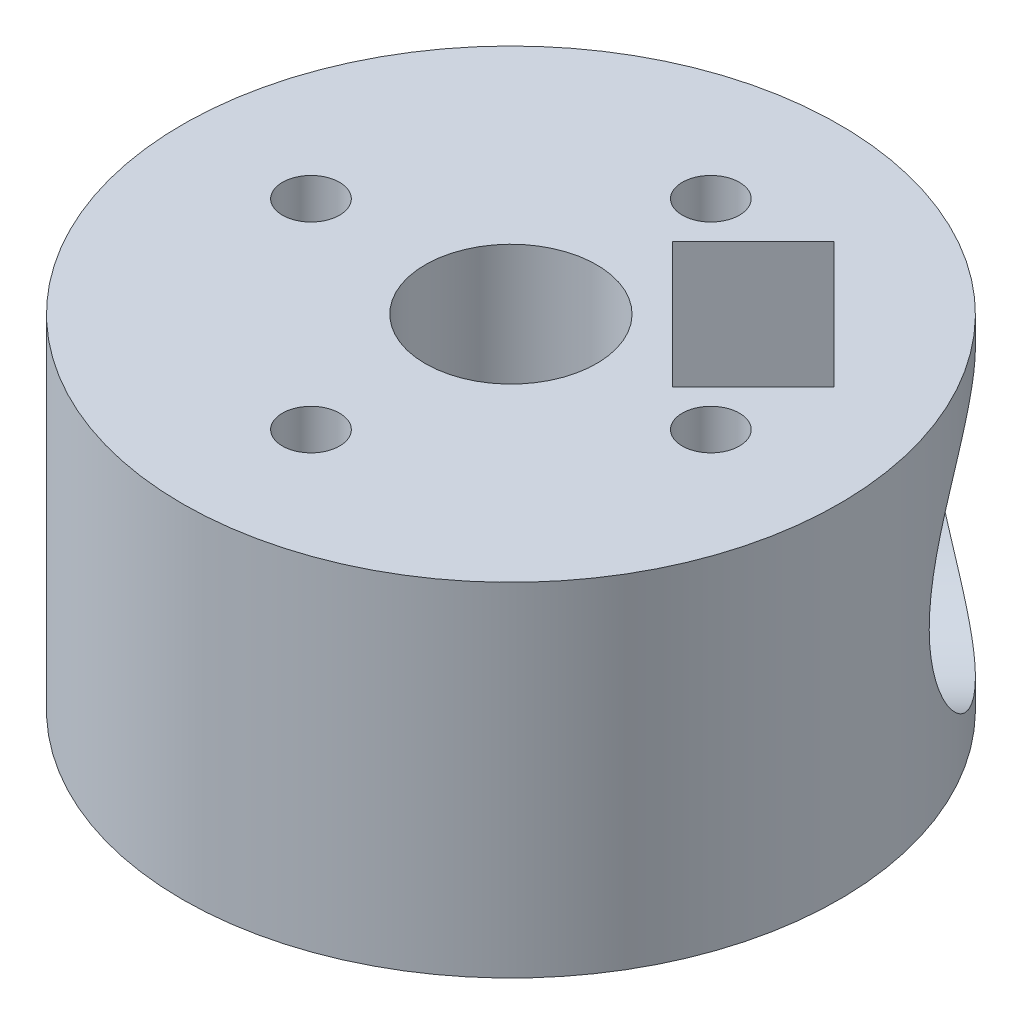
from build123d import *

# Parameters (mm, degrees)
CROQUIS1_R              = 11.5
CROQUIS1_R_2            = 3
CROQUIS1_R_3            = 1
SALIENTE_EXTRUIR1_DEPTH = 12
CORTAR_EXTRUIR1_DEPTH   = 13
CORTAR_EXTRUIR2_START   = 10
CROQUIS3_R              = 1.5
CORTAR_EXTRUIR2_DEPTH   = 12
CORTAR_EXTRUIR3_START   = 10
CROQUIS4_R              = 5
CORTAR_EXTRUIR3_DEPTH   = 4


with BuildPart() as part:
    # Croquis1 → Saliente-Extruir1 (new body)
    with BuildSketch(Plane(origin=(0, 0, 0), x_dir=(1, 0, 0), z_dir=(0, 1, 0))):
        Circle(CROQUIS1_R)
        Circle(CROQUIS1_R_2, mode=Mode.SUBTRACT)
        with Locations((0, 7)):
            Circle(CROQUIS1_R_3, mode=Mode.SUBTRACT)
        with Locations((7, 0)):
            Circle(CROQUIS1_R_3, mode=Mode.SUBTRACT)
        with Locations((0, -7)):
            Circle(CROQUIS1_R_3, mode=Mode.SUBTRACT)
        with Locations((-7, 0)):
            Circle(CROQUIS1_R_3, mode=Mode.SUBTRACT)
    extrude(amount=SALIENTE_EXTRUIR1_DEPTH)

    # Croquis2 → Cortar-Extruir1 (cut, through all)
    with BuildSketch(Plane(origin=(0, 12, 0), x_dir=(1, 0, 0), z_dir=(0, 1, 0))):
        Polygon((7.866562941, 3.447145558), (5.038135816, 0.618718434), (2.828427125, 2.828427125), (5.656854249, 5.656854249), align=None)
        Polygon((5.656854249, 5.656854249), (3.447145558, 7.866562941), (0.618718434, 5.038135816), (2.828427125, 2.828427125), align=None)
    extrude(amount=-CORTAR_EXTRUIR1_DEPTH, mode=Mode.SUBTRACT)

    # Croquis3 → Cortar-Extruir2 (cut)
    with BuildSketch(Plane(origin=(2.828427125, 0, -2.828427125), x_dir=(-0.707106781, 0, -0.707106781), z_dir=(0.707106781, 0, -0.707106781)).offset(CORTAR_EXTRUIR2_START)):
        with Locations((0, 6)):
            Circle(CROQUIS3_R)
    extrude(amount=-CORTAR_EXTRUIR2_DEPTH, mode=Mode.SUBTRACT)

    # Croquis4 → Cortar-Extruir3 (cut)
    with BuildSketch(Plane(origin=(2.828427125, 0, -2.828427125), x_dir=(-0.707106781, 0, -0.707106781), z_dir=(0.707106781, 0, -0.707106781)).offset(CORTAR_EXTRUIR3_START)):
        with Locations((0, 6)):
            Circle(CROQUIS4_R)
    extrude(amount=-CORTAR_EXTRUIR3_DEPTH, mode=Mode.SUBTRACT)


solid = part.part
